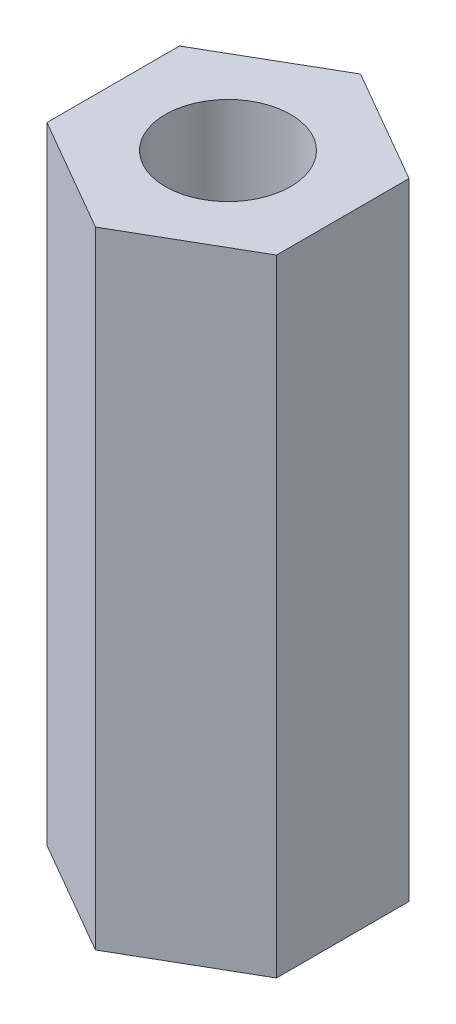
from build123d import *

# Parameters (mm, degrees)
SKETCH_1_R      = 1.5
EXTRUDE_1_DEPTH = 15


with BuildPart() as part:
    # Эскиз1 → Бобышка-Вытянуть1 (new body)
    with BuildSketch(Plane(origin=(0, 0, 0), x_dir=(1, 0, 0), z_dir=(0, 1, 0))):
        Polygon((0, 3.175426481), (-2.75, 1.58771324), (-2.75, -1.58771324), (0, -3.175426481), (2.75, -1.58771324), (2.75, 1.58771324), align=None)
        Circle(SKETCH_1_R, mode=Mode.SUBTRACT)
    extrude(amount=EXTRUDE_1_DEPTH)


solid = part.part
